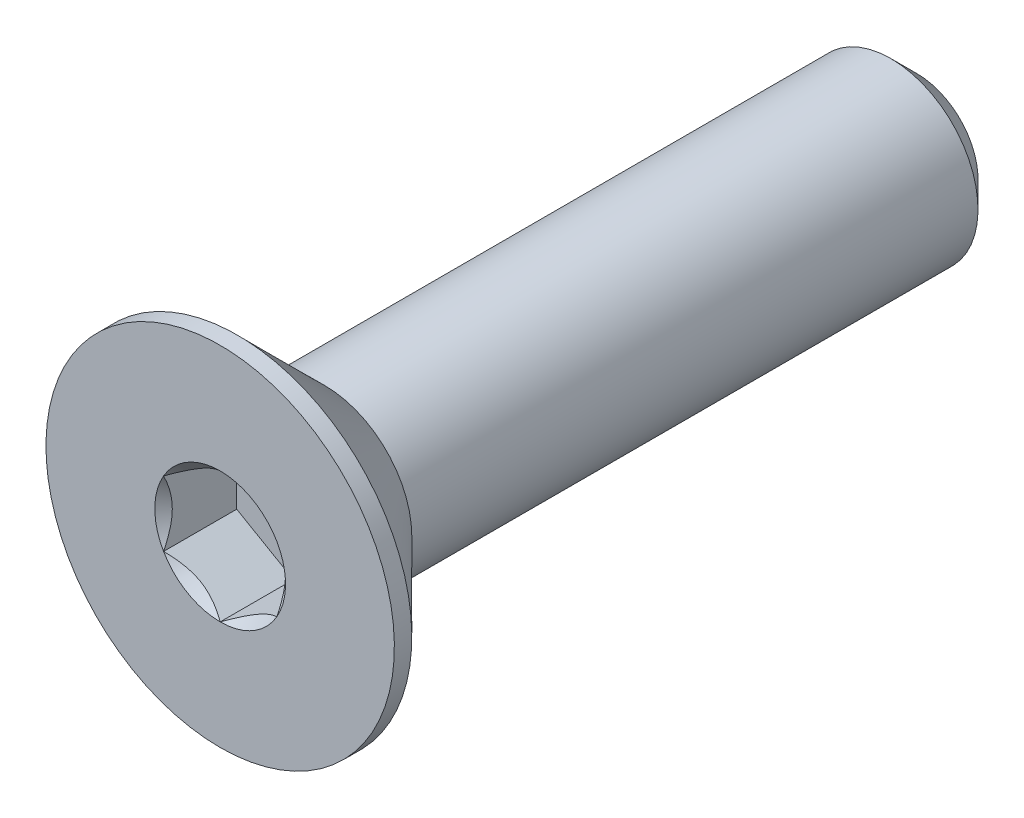
from build123d import *

# Parameters (mm, degrees)
SKETCH1_W          = 8
SKETCH1_H          = 1
CHAMFER1_SIZE      = 0.3
CUT_EXTRUDE2_DEPTH = 0.84


with BuildPart() as part:
    # Sketch1 → Revolve1 (revolve)
    with BuildSketch(Plane(origin=(0, 0, 0), x_dir=(0, 0, -1), z_dir=(1, 0, 0))):
        with Locations((4, 0.5)):
            Rectangle(SKETCH1_W, SKETCH1_H)
    revolve(axis=Axis((0, 0, -8), (0, 0, 1)))

    # Chamfer1
    chamfer1_edges = [part.edges().sort_by_distance(p)[0] for p in [
        (0, -1, -8),
    ]]
    chamfer(chamfer1_edges, length=CHAMFER1_SIZE)

    # Sketch7 → Revolve2 (revolve)
    with BuildSketch(Plane(origin=(0, 0, 0), x_dir=(0, 0, -1), z_dir=(1, 0, 0)), mode=Mode.PRIVATE) as revolve2_sk:
        Polygon((0, 2), (0.2, 2), (1.2, 1), (1.2, 0), (0, 0), align=None)
    revolve(revolve2_sk.sketch.rotate(Axis((0, 0, 0), (0, 0, -1)), 180), axis=Axis((0, 0, 0), (0, 0, -1)))

    # Boss-Extrude1 cone 1 section (through the dimple's axis) → Boss-Extrude1 (revolve)
    with BuildSketch(Plane(origin=(0, 0, -1.2), x_dir=(0, -1, 0), z_dir=(1, 0, 0))):
        Polygon((0, 0), (1, 0), (0, 1), align=None)
    revolve(axis=Axis((0, 0, -1.2), (0, 0, -1)))

    # Sketch5 → Cut-Extrude2 (cut)
    with BuildSketch(Plane.XY):
        Polygon((0.65, -0.375277675), (0.65, 0.375277675), (0, 0.75055535), (-0.65, 0.375277675), (-0.65, -0.375277675), (0, -0.75055535), align=None)
    extrude(amount=-CUT_EXTRUDE2_DEPTH, mode=Mode.SUBTRACT)

    # Cut-Extrude3 cone 1 section (through the dimple's axis) → Cut-Extrude3 (revolve, cut)
    with BuildSketch(Plane(origin=(0, 0, 0), x_dir=(0, -1, 0), z_dir=(1, 0, 0))):
        Polygon((0, 0), (0.75055535, 0), (0, 0.75055535), align=None)
    revolve(axis=Axis((0, 0, 0), (0, 0, -1)), mode=Mode.SUBTRACT)


solid = part.part
